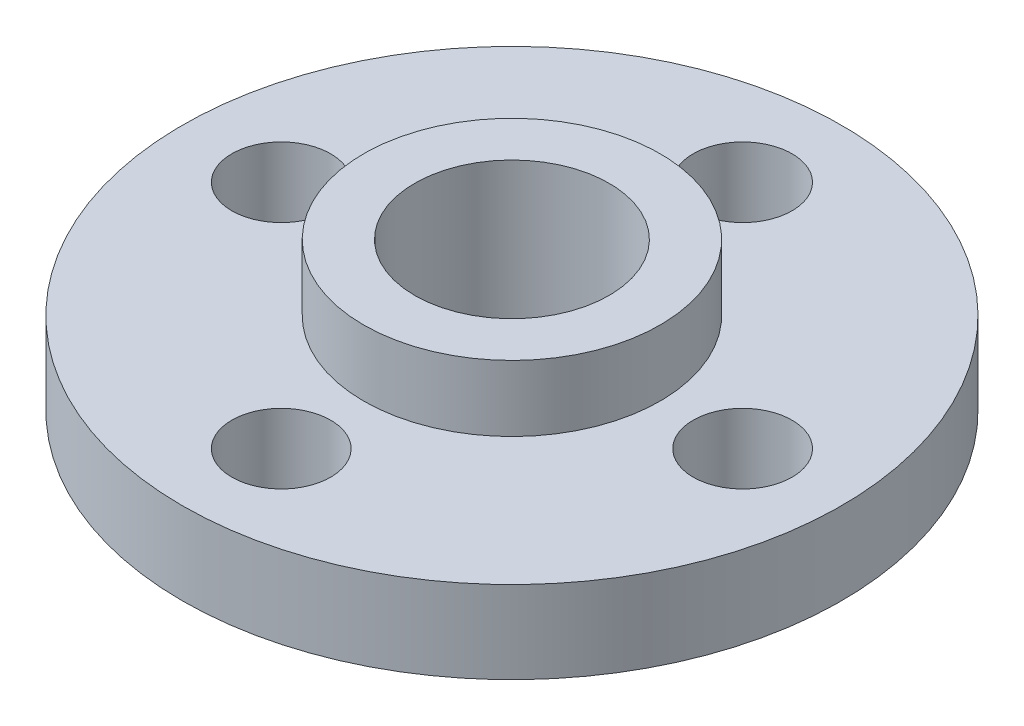
from build123d import *

# Parameters (mm, degrees)
SKETCH_1_R      = 10
SKETCH_1_R_2    = 1.5
SKETCH_1_R_3    = 2.95
EXTRUDE_1_DEPTH = 2.5
SKETCH_2_R      = 4.5
SKETCH_2_R_2    = 2.95
EXTRUDE_2_DEPTH = 2


with BuildPart() as part:
    # Эскиз1 → Бобышка-Вытянуть1 (new body)
    with BuildSketch(Plane(origin=(0, 0, 0), x_dir=(1, 0, 0), z_dir=(0, 1, 0))):
        Circle(SKETCH_1_R)
        with Locations((-7, 0)):
            Circle(SKETCH_1_R_2, mode=Mode.SUBTRACT)
        with Locations((0, 7)):
            Circle(SKETCH_1_R_2, mode=Mode.SUBTRACT)
        with Locations((0, -7)):
            Circle(SKETCH_1_R_2, mode=Mode.SUBTRACT)
        with Locations((7, 0)):
            Circle(SKETCH_1_R_2, mode=Mode.SUBTRACT)
        Circle(SKETCH_1_R_3, mode=Mode.SUBTRACT)
    extrude(amount=EXTRUDE_1_DEPTH)

    # Эскиз2 → Бобышка-Вытянуть2 (add)
    with BuildSketch(Plane(origin=(0, 2.5, 0), x_dir=(1, 0, 0), z_dir=(0, 1, 0))):
        Circle(SKETCH_2_R)
        Circle(SKETCH_2_R_2, mode=Mode.SUBTRACT)
    extrude(amount=EXTRUDE_2_DEPTH)


solid = part.part
